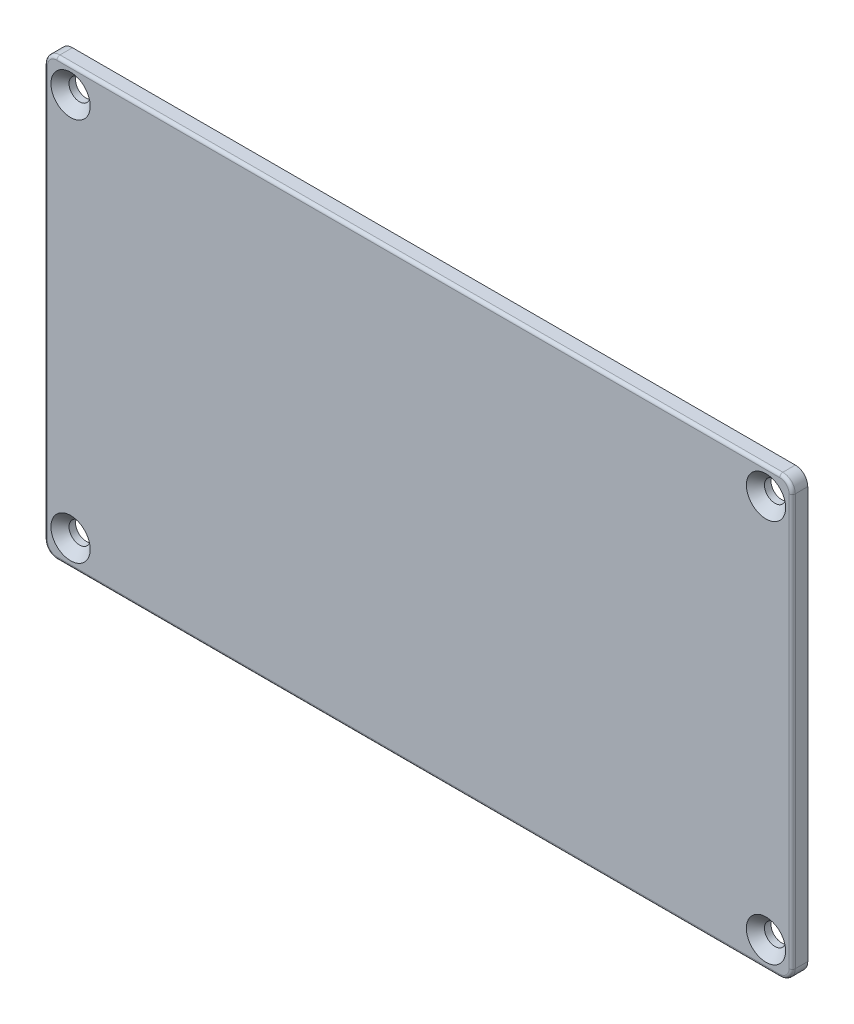
from build123d import *

# Parameters (mm, degrees)
SKETCH1_W                                           = 120
SKETCH1_H                                           = 70
BOSS_EXTRUDE1_DEPTH                                 = 2.5
FILLET1_R                                           = 2
CSK_FOR_M3_COUNTERSUNK_FLAT_HEAD_SCREW1_D           = 3.4
CSK_FOR_M3_COUNTERSUNK_FLAT_HEAD_SCREW1_DEPTH       = 10
CSK_FOR_M3_COUNTERSUNK_FLAT_HEAD_SCREW1_CSINK_D     = 6.3
CSK_FOR_M3_COUNTERSUNK_FLAT_HEAD_SCREW1_CSINK_ANGLE = 90
CSK_FOR_M3_COUNTERSUNK_FLAT_HEAD_SCREW1_TIP         = 1.021463052
FILLET2_R                                           = 0.5


with BuildPart() as part:
    # Sketch1 → Boss-Extrude1 (new body)
    with BuildSketch(Plane.XY):
        Rectangle(SKETCH1_W, SKETCH1_H)
    extrude(amount=BOSS_EXTRUDE1_DEPTH)

    # Fillet1
    fillet1_edges = [part.edges().sort_by_distance(p)[0] for p in [
        (-60, 35, 1.25),
        (60, 35, 1.25),
        (60, -35, 1.25),
        (-60, -35, 1.25),
    ]]
    fillet(fillet1_edges, radius=FILLET1_R)

    # CSK for M3 Countersunk Flat Head Screw1
    with Locations(Plane(origin=(-55.8, 30.8, 2.5), x_dir=(1, 0, 0), z_dir=(0, 0, 1))):
        with Locations((0, 0), (111.6, 0), (111.6, -61.6), (0, -61.6)):
            CounterSinkHole(CSK_FOR_M3_COUNTERSUNK_FLAT_HEAD_SCREW1_D / 2, CSK_FOR_M3_COUNTERSUNK_FLAT_HEAD_SCREW1_CSINK_D / 2, depth=CSK_FOR_M3_COUNTERSUNK_FLAT_HEAD_SCREW1_DEPTH, counter_sink_angle=CSK_FOR_M3_COUNTERSUNK_FLAT_HEAD_SCREW1_CSINK_ANGLE)
            with Locations((0, 0, -(CSK_FOR_M3_COUNTERSUNK_FLAT_HEAD_SCREW1_DEPTH + CSK_FOR_M3_COUNTERSUNK_FLAT_HEAD_SCREW1_TIP / 2))):  # 118° drill point
                Cone(0, CSK_FOR_M3_COUNTERSUNK_FLAT_HEAD_SCREW1_D / 2, CSK_FOR_M3_COUNTERSUNK_FLAT_HEAD_SCREW1_TIP, mode=Mode.SUBTRACT)

    # Fillet2
    fillet2_edges = [part.edges().sort_by_distance(p)[0] for p in [
        (60, 0, 2.5),
        (0, -35, 2.5),
        (-60, 0, 2.5),
        (0, 35, 2.5),
        (59.414213562, 34.414213562, 2.5),
        (-59.414213562, 34.414213562, 2.5),
        (-59.414213562, -34.414213562, 2.5),
        (59.414213562, -34.414213562, 2.5),
    ]]
    fillet(fillet2_edges, radius=FILLET2_R)


solid = part.part
